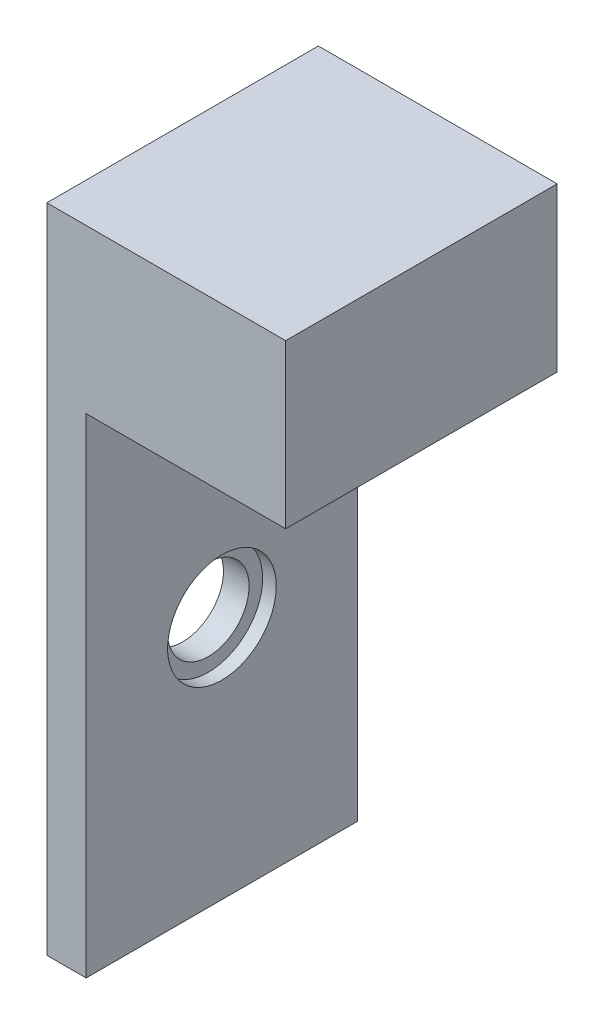
from build123d import *

# Parameters (mm, degrees)
ESQUISSE1_W             = 30
ESQUISSE1_H             = 24
BOSS_EXTRU_1_DEPTH      = 10
ESQUISSE2_W             = 20
ESQUISSE2_H             = 20
ENL_V_MAT_EXTRU_1_DEPTH = 10
ESQUISSE3_W             = 7.346397708
ESQUISSE3_H             = 18
ENL_V_MAT_EXTRU_2_DEPTH = 10
ESQUISSE5_W             = 21.205400457
ESQUISSE5_H             = 24
ENL_V_MAT_EXTRU_3_DEPTH = 10
ESQUISSE6_R             = 2
ENL_V_MAT_EXTRU_4_DEPTH = 0.5
ESQUISSE7_R             = 1.5
ENL_V_MAT_EXTRU_5_DEPTH = 10.5


with BuildPart() as part:
    # Esquisse1 → Boss.-Extru.1 (new body)
    with BuildSketch(Plane.XY):
        with Locations((3.298240101, -8.976744186)):
            Rectangle(ESQUISSE1_W, ESQUISSE1_H)
    extrude(amount=BOSS_EXTRU_1_DEPTH)

    # Esquisse2 → Enlèv. mat.-Extru.1 (cut)
    with BuildSketch(Plane.XY.offset(10)):
        with Locations((-0.490787108, -8.976744186)):
            Rectangle(ESQUISSE2_W, ESQUISSE2_H)
    extrude(amount=-ENL_V_MAT_EXTRU_1_DEPTH, mode=Mode.SUBTRACT)

    # Esquisse3 → Enlèv. mat.-Extru.2 (cut)
    with BuildSketch(Plane.XY.offset(10)):
        with Locations((14.625041247, -11.976744186)):
            Rectangle(ESQUISSE3_W, ESQUISSE3_H)
    extrude(amount=-ENL_V_MAT_EXTRU_2_DEPTH, mode=Mode.SUBTRACT)

    # Esquisse5 → Enlèv. mat.-Extru.3 (cut)
    with BuildSketch(Plane.XY.offset(10)):
        with Locations((-1.09905967, -8.976744186)):
            Rectangle(ESQUISSE5_W, ESQUISSE5_H)
    extrude(amount=-ENL_V_MAT_EXTRU_3_DEPTH, mode=Mode.SUBTRACT)

    # Esquisse6 → Enlèv. mat.-Extru.4 (cut)
    with BuildSketch(Plane(origin=(10.951842393, 0, 0), x_dir=(0, 0, -1), z_dir=(1, 0, 0))):
        with Locations((-5, -11.976744186)):
            Circle(ESQUISSE6_R)
    extrude(amount=-ENL_V_MAT_EXTRU_4_DEPTH, mode=Mode.SUBTRACT)

    # Esquisse7 → Enlèv. mat.-Extru.5 (cut)
    with BuildSketch(Plane(origin=(10.451842393, 0, 0), x_dir=(0, 0, -1), z_dir=(1, 0, 0))):
        with Locations((-5, -11.976744186)):
            Circle(ESQUISSE7_R)
    extrude(amount=-ENL_V_MAT_EXTRU_5_DEPTH, mode=Mode.SUBTRACT)


solid = part.part
